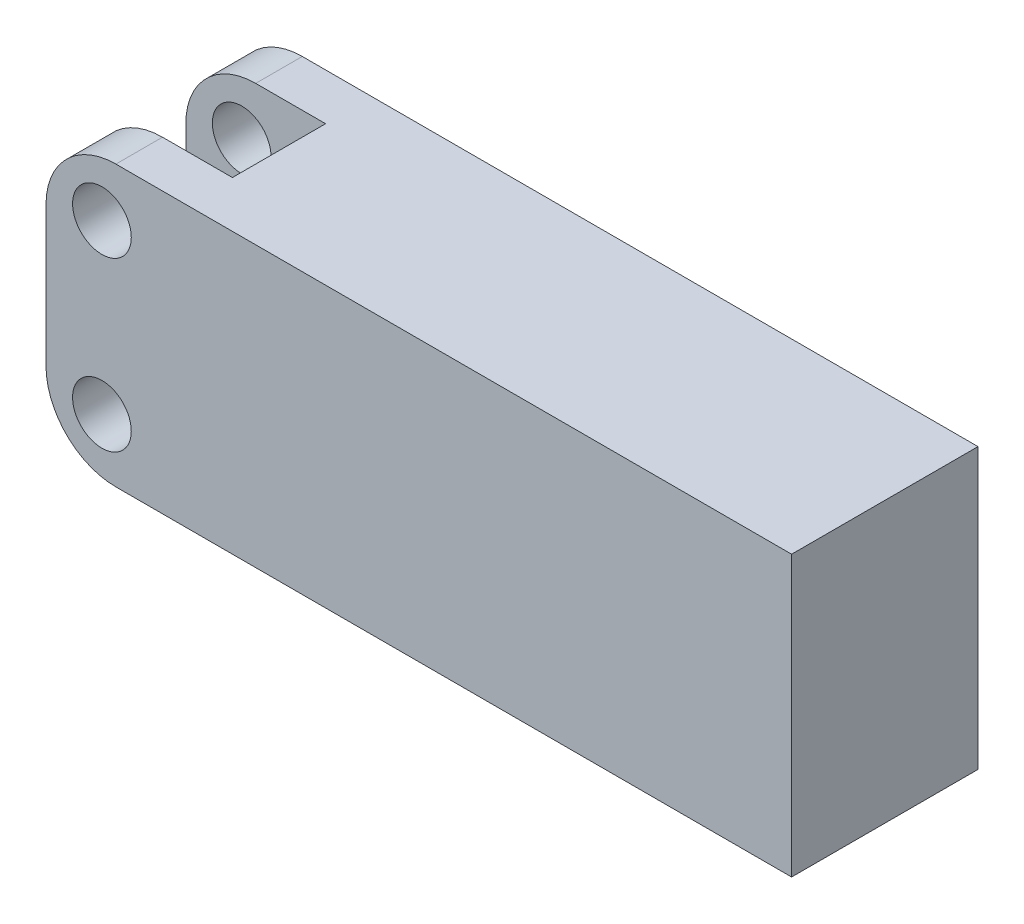
from build123d import *

# Parameters (mm, degrees)
SKETCH1_W           = 50.8
SKETCH1_H           = 19.05
SKETCH1_R           = 2
BOSS_EXTRUDE1_DEPTH = 12.7
SKETCH2_W           = 9.525
SKETCH2_H           = 6.35
CUT_EXTRUDE1_DEPTH  = 10.5
FILLET1_R           = 4.7625
FILLET2_R           = 4.7625


with BuildPart() as part:
    # Sketch1 → Boss-Extrude1 (new body)
    with BuildSketch(Plane.XY):
        with Locations((25.4, 9.525)):
            Rectangle(SKETCH1_W, SKETCH1_H)
        with Locations((3.81, 3.81)):
            Circle(SKETCH1_R, mode=Mode.SUBTRACT)
        with Locations((3.81, 15.24)):
            Circle(SKETCH1_R, mode=Mode.SUBTRACT)
    extrude(amount=BOSS_EXTRUDE1_DEPTH)

    # Sketch2 → Cut-Extrude1 (cut)
    with BuildSketch(Plane(origin=(0, 19.05, 0), x_dir=(1, 0, 0), z_dir=(0, 1, 0))):
        with Locations((4.7625, -6.35)):
            Rectangle(SKETCH2_W, SKETCH2_H)
    extrude(amount=-CUT_EXTRUDE1_DEPTH, mode=Mode.SUBTRACT)

    # Fillet1
    fillet1_edges = [part.edges().sort_by_distance(p)[0] for p in [
        (9.525, 8.55, 6.35),
    ]]
    fillet(fillet1_edges, radius=FILLET1_R)

    # Fillet2
    fillet2_edges = [part.edges().sort_by_distance(p)[0] for p in [
        (0, 19.05, 1.5875),
        (0, 19.05, 11.1125),
        (0, 0, 6.35),
    ]]
    fillet(fillet2_edges, radius=FILLET2_R)


solid = part.part
